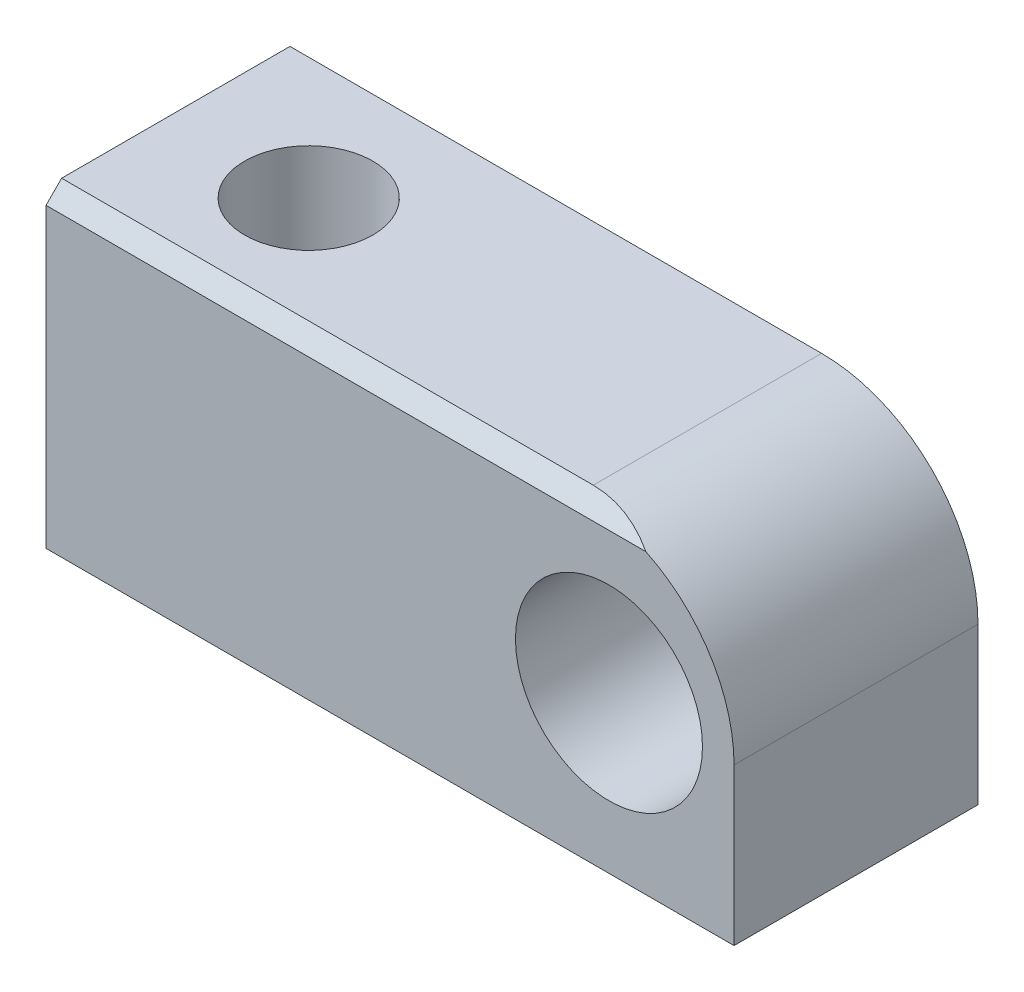
from build123d import *

# Parameters (mm, degrees)
ESQUISSE1_R             = 2.99
EXTRUSION1_DEPTH        = 3.9
ESQUISSE2_R             = 2.05
ENL_V_MAT_EXTRU_1_DEPTH = 11
ENL_V_MAT_EXTRU_2_DEPTH = 23


with BuildPart() as part:
    # Esquisse1 → Extrusion1 (new body, symmetric)
    with BuildSketch(Plane.XY):
        with BuildLine():
            Line((0, 0), (-22, 0))
            Line((-22, 0), (-22, 10))
            Line((-22, 10), (-5, 10))
            ThreePointArc((-5, 10), (-1.464466094, 8.535533906), (0, 5))
            Line((0, 5), (0, 0))
        make_face()
        with Locations((-4, 5)):
            Circle(ESQUISSE1_R, mode=Mode.SUBTRACT)
    extrude(amount=EXTRUSION1_DEPTH, both=True)

    # Esquisse2 → Enlèv. mat.-Extru.1 (cut, through all)
    with BuildSketch(Plane.XZ):
        with Locations((-17.5, 0)):
            Circle(ESQUISSE2_R)
    extrude(amount=-ENL_V_MAT_EXTRU_1_DEPTH, mode=Mode.SUBTRACT)

    # Esquisse3 → Enlèv. mat.-Extru.2 (cut, through all)
    with BuildSketch(Plane.ZY.offset(22)):
        Polygon((3.9, 10), (3.9, 9.5), (3.4, 10), align=None)
    extrude(amount=-ENL_V_MAT_EXTRU_2_DEPTH, mode=Mode.SUBTRACT)


solid = part.part
